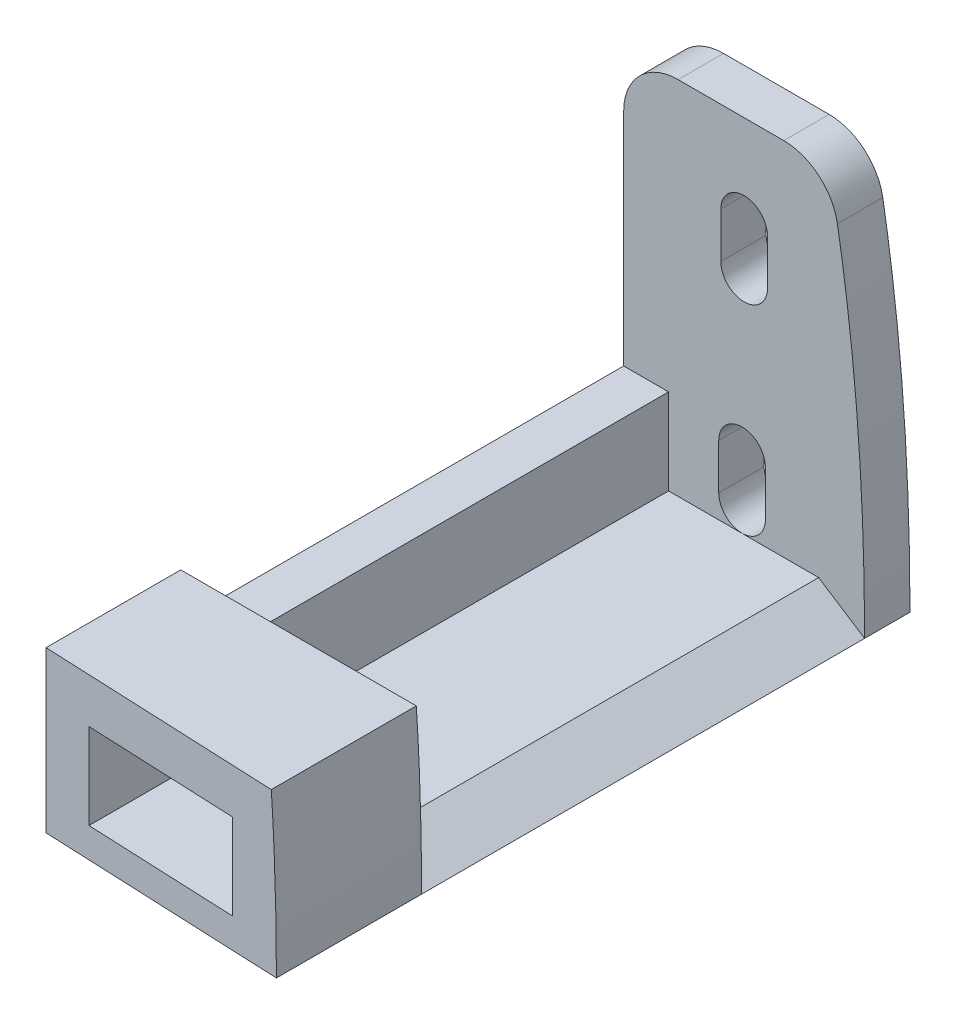
from build123d import *

# Parameters (mm, degrees)
BOSS_EXTRUDE1_DEPTH = 3.175
BOSS_EXTRUDE2_DEPTH = 41.15
SKETCH3_W           = 10.5
SKETCH3_H           = 6
BOSS_EXTRUDE3_DEPTH = 10.16
CUT_EXTRUDE1_DEPTH  = 39.555801056


with BuildPart() as part:
    # Sketch1 → Boss-Extrude1 (new body)
    with BuildSketch(Plane.XY):
        with BuildLine():
            Line((71.045544716, 27.335394647), (63.656604316, 27.335394647))
            ThreePointArc((63.656604316, 27.335394647), (60.962527479, 26.219471483), (59.846604316, 23.525394647))
            Line((59.846604316, 23.525394647), (59.846604316, -23.525394647))
            ThreePointArc((59.846604316, -23.525394647), (60.962527479, -26.219471483), (63.656604316, -27.335394647))
            Line((63.656604316, -27.335394647), (71.045544716, -27.335394647))
            ThreePointArc((71.045544716, -27.335394647), (73.499934786, -26.439510188), (74.800072929, -24.173173852))
            add(Edge.make_bspline(
                [(76.701202739, 0), (76.701202739, -8.04022214), (76.161781205, -16.280712803), (74.800072929, -24.173173852)],
                knots=[0, 0, 0, 0, 0.259951787, 0.259951787, 0.259951787, 0.259951787], degree=3))
            add(Edge.make_bspline(
                [(74.800072929, 24.173173852), (76.161781205, 16.280712803), (76.701202739, 8.04022214), (76.701202739, 0)],
                knots=[0.740048213, 0.740048213, 0.740048213, 0.740048213, 1, 1, 1, 1], degree=3))
            ThreePointArc((74.800072929, 24.173173852), (73.499934786, 26.439510188), (71.045544716, 27.335394647))
        make_face()
        with BuildLine():
            Line((66.641953527, -20.985394647), (66.641953527, -17.810394647))
            ThreePointArc((66.641953527, -17.810394647), (68.273903527, -16.178444647), (69.905853527, -17.810394647))
            Line((69.905853527, -17.810394647), (69.905853527, -20.985394647))
            ThreePointArc((69.905853527, -20.985394647), (68.273903527, -22.617344647), (66.641953527, -20.985394647))
        make_face(mode=Mode.SUBTRACT)
        with BuildLine():
            Line((66.497091774, -6.896821773), (66.497091774, -3.721821773))
            ThreePointArc((66.497091774, -3.721821773), (68.129041774, -2.089871773), (69.760991774, -3.721821773))
            Line((69.760991774, -3.721821773), (69.760991774, -6.896821773))
            ThreePointArc((69.760991774, -6.896821773), (68.129041774, -8.528771773), (66.497091774, -6.896821773))
        make_face(mode=Mode.SUBTRACT)
        with BuildLine():
            Line((66.641953527, 20.985394647), (66.641953527, 17.810394647))
            ThreePointArc((66.641953527, 17.810394647), (68.273903527, 16.178444647), (69.905853527, 17.810394647))
            Line((69.905853527, 17.810394647), (69.905853527, 20.985394647))
            ThreePointArc((69.905853527, 20.985394647), (68.273903527, 22.617344647), (66.641953527, 20.985394647))
        make_face(mode=Mode.SUBTRACT)
        with BuildLine():
            Line((66.497091774, 6.896821773), (66.497091774, 3.721821773))
            ThreePointArc((66.497091774, 3.721821773), (68.129041774, 2.089871773), (69.760991774, 3.721821773))
            Line((69.760991774, 3.721821773), (69.760991774, 6.896821773))
            ThreePointArc((69.760991774, 6.896821773), (68.129041774, 8.528771773), (66.497091774, 6.896821773))
        make_face(mode=Mode.SUBTRACT)
    extrude(amount=BOSS_EXTRUDE1_DEPTH)

    # Sketch2 → Boss-Extrude2 (add)
    with BuildSketch(Plane.XY.offset(3.175)):
        Polygon((76.701202739, 0), (73.487010624, 2.08), (62.987010624, 2.08), (62.987010624, 8.08), (59.846604316, 8.08), (59.846604316, -8.08), (62.987010624, -8.08), (62.987010624, -2.08), (73.487010624, -2.08), align=None)
    extrude(amount=BOSS_EXTRUDE2_DEPTH)

    # Sketch3 → Boss-Extrude3 (add)
    with BuildSketch(Plane.XY.offset(44.325)):
        with BuildLine():
            Line((59.846604316, 8.08), (59.846604316, 11.220406309))
            Line((59.846604316, 11.220406309), (76.327728698, 11.220406308))
            add(Edge.make_bspline(
                [(76.701202739, 0), (76.701202739, 3.71540513), (76.586015455, 7.473575307), (76.327728698, 11.220406308)],
                knots=[0, 0, 0, 0, 0.120124318, 0.120124318, 0.120124318, 0.120124318], degree=3))
            add(Edge.make_bspline(
                [(76.701202739, 0), (76.701202739, -3.71540513), (76.586015455, -7.473575307), (76.327728698, -11.220406308)],
                knots=[0, 0, 0, 0, 0.120124318, 0.120124318, 0.120124318, 0.120124318], degree=3))
            Line((76.327728698, -11.220406308), (59.846604316, -11.220406309))
            Line((59.846604316, -11.220406309), (59.846604316, -8.08))
            Line((59.846604316, -8.08), (59.846604316, 8.08))
        make_face()
        with Locations((68.237010624, 5.08)):
            Rectangle(SKETCH3_W, SKETCH3_H, mode=Mode.SUBTRACT)
        with Locations((68.237010624, -5.08)):
            Rectangle(SKETCH3_W, SKETCH3_H, mode=Mode.SUBTRACT)
    extrude(amount=-BOSS_EXTRUDE3_DEPTH)

    # Sketch4 → Cut-Extrude1 (cut, through all)
    with BuildSketch(Plane(origin=(0, 11.220406309, 0), x_dir=(1, 0, 0), z_dir=(0, 1, 0))):
        Polygon((76.701202739, -44.325), (59.846604316, -43.589112341), (59.846604316, -44.325), align=None)
    extrude(amount=-CUT_EXTRUDE1_DEPTH, mode=Mode.SUBTRACT)


with BuildPart() as body_2:
    # Split1: the piece on the far side of the plane
    add(part.part)
    split(bisect_by=Plane(origin=(0, 0, 0), x_dir=(1, 0, 0), z_dir=(0, 1, 0)), keep=Keep.BOTTOM)


with BuildPart() as part_1:
    add(part.part)

    # Split1
    split(bisect_by=Plane(origin=(0, 0, 0), x_dir=(1, 0, 0), z_dir=(0, 1, 0)), keep=Keep.TOP)


solid = part_1.part
